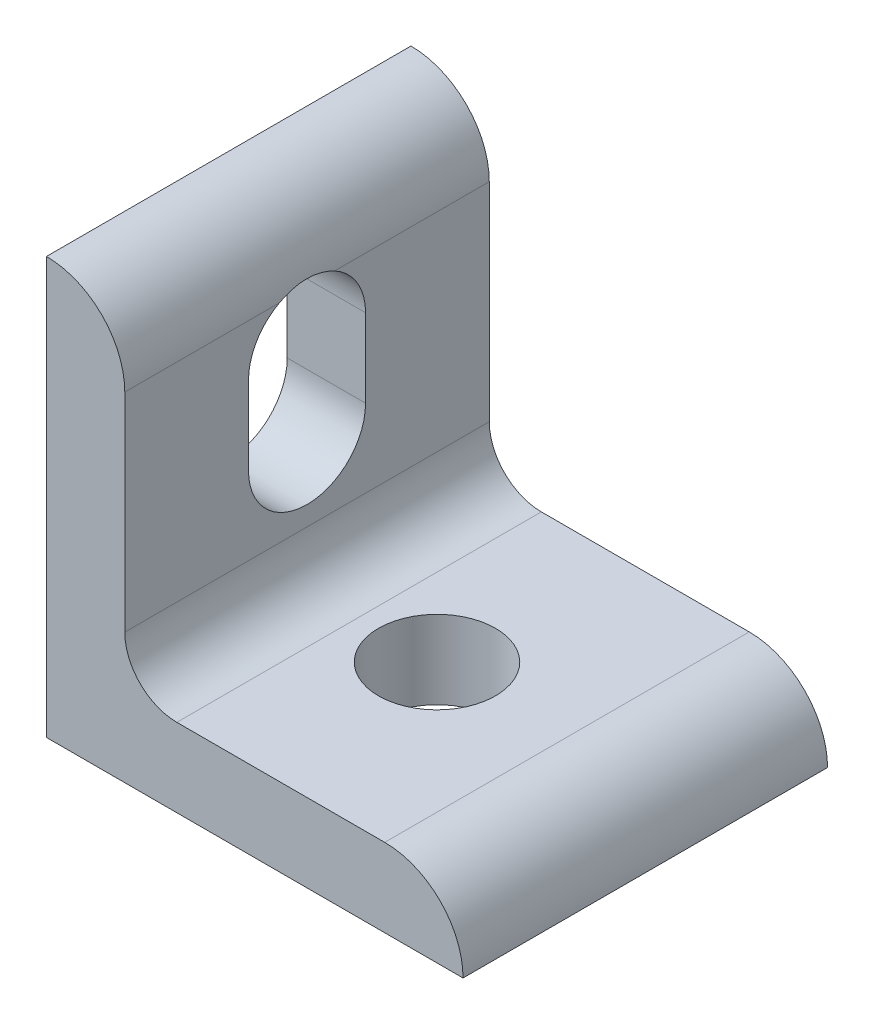
from build123d import *

# Parameters (mm, degrees)
BOSS_EXTRUDE1_DEPTH      = 11.1125
BOSS_EXTRUDE1_DEPTH_BACK = 11.1125
CUT_EXTRUDE1_DEPTH       = 21.6248
CUT_EXTRUDE1_DEPTH_BACK  = 5.7752
SKETCH6_R                = 3.5687
CUT_EXTRUDE2_DEPTH       = 5.7752


with BuildPart() as part:
    # Sketch4 → Boss-Extrude1 (new body, two sides)
    with BuildSketch(Plane.XY) as boss_extrude1_sk:
        with BuildLine():
            Line((-12.7, 12.7), (-12.7, -12.7))
            Line((-12.7, -12.7), (12.7, -12.7))
            ThreePointArc((12.7, -12.7), (11.301376302, -9.323423698), (7.9248, -7.9248))
            Line((7.9248, -7.9248), (-4.7498, -7.9248))
            ThreePointArc((-4.7498, -7.9248), (-6.99486403, -6.99486403), (-7.9248, -4.7498))
            Line((-7.9248, -4.7498), (-7.9248, 7.9248))
            ThreePointArc((-7.9248, 7.9248), (-9.323423698, 11.301376302), (-12.7, 12.7))
        make_face()
    extrude(amount=BOSS_EXTRUDE1_DEPTH)
    extrude(boss_extrude1_sk.sketch, amount=-BOSS_EXTRUDE1_DEPTH_BACK)

    # Sketch5 → Cut-Extrude1 (cut, two sides)
    with BuildSketch(Plane(origin=(-7.9248, 0, 0), x_dir=(0, 0, -1), z_dir=(1, 0, 0))) as cut_extrude1_sk:
        with BuildLine():
            Line((3.5687, 4.7752), (3.5687, 0))
            ThreePointArc((3.5687, 0), (0, -3.5687), (-3.5687, 0))
            Line((-3.5687, 0), (-3.5687, 4.7752))
            ThreePointArc((-3.5687, 4.7752), (0, 8.3439), (3.5687, 4.7752))
        make_face()
    extrude(amount=CUT_EXTRUDE1_DEPTH, mode=Mode.SUBTRACT)
    extrude(cut_extrude1_sk.sketch, amount=-CUT_EXTRUDE1_DEPTH_BACK, mode=Mode.SUBTRACT)

    # Sketch6 → Cut-Extrude2 (cut, through all)
    with BuildSketch(Plane(origin=(0, -7.9248, 0), x_dir=(1, 0, 0), z_dir=(0, 1, 0))):
        Circle(SKETCH6_R)
    extrude(amount=-CUT_EXTRUDE2_DEPTH, mode=Mode.SUBTRACT)


solid = part.part
